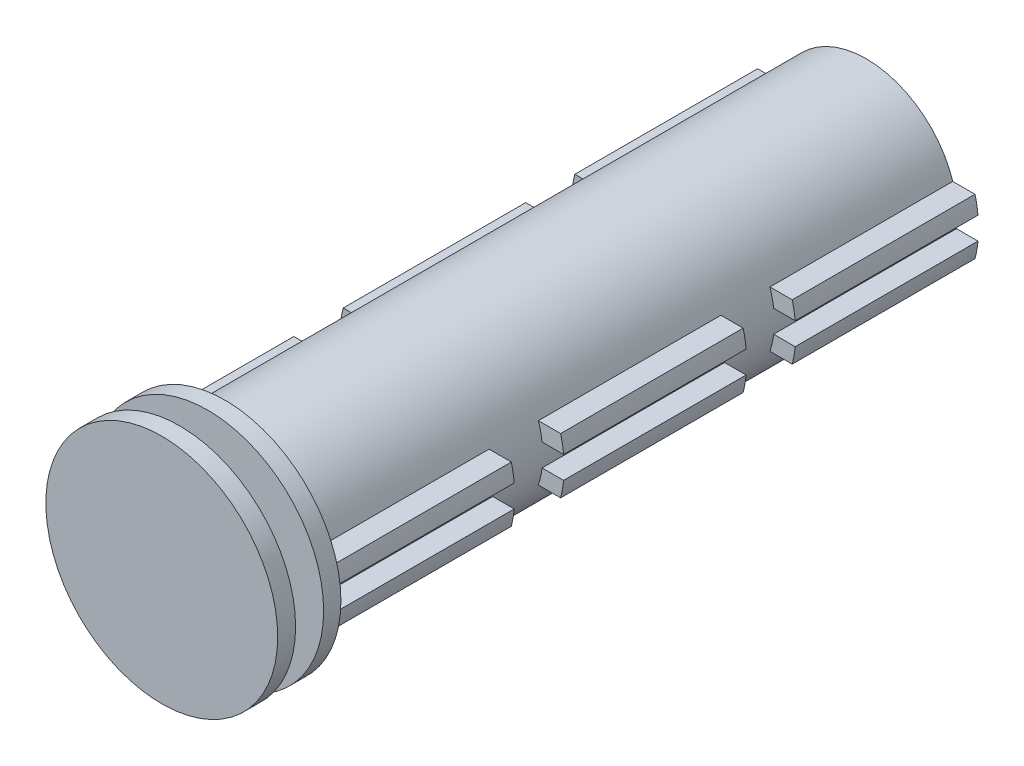
from build123d import *

# Parameters (mm, degrees)
SKETCH1_R           = 9.35355
BOSS_EXTRUDE1_DEPTH = 66.04
SKETCH7_R           = 11.938
BOSS_EXTRUDE4_DEPTH = 1.778
SKETCH14_R          = 7.71525
CUT_EXTRUDE1_DEPTH  = 66.04
SKETCH12_W          = 18.288
SKETCH12_H          = 1.7145
SKETCH12_H_2        = 1.707763716
SKETCH12_W_2        = 18.824802472
SKETCH12_W_3        = 18.796
BOSS_EXTRUDE5_DEPTH = 2.8448
CUT_EXTRUDE2_DEPTH  = 66.04
SKETCH21_R          = 7.399529871
BOSS_EXTRUDE7_DEPTH = 2.8448
SKETCH22_R          = 11.938
BOSS_EXTRUDE8_DEPTH = 1.8415
CUT_EXTRUDE3_DEPTH  = 66.04


with BuildPart() as part:
    # Sketch1 → Boss-Extrude1 (new body)
    with BuildSketch(Plane.XY):
        with Locations((-78.519529871, 2.741262574)):
            Circle(SKETCH1_R)
    extrude(amount=BOSS_EXTRUDE1_DEPTH)

    # Sketch7 → Boss-Extrude4 (add)
    with BuildSketch(Plane.XY.offset(66.04)):
        with Locations((-78.519529871, 2.741262574)):
            Circle(SKETCH7_R)
    extrude(amount=BOSS_EXTRUDE4_DEPTH)

    # Sketch14 → Cut-Extrude1 (cut)
    with BuildSketch(Plane(origin=(0, 0, 0), x_dir=(-1, 0, 0), z_dir=(0, 0, -1))):
        with Locations((78.519529871, 2.741262574)):
            Circle(SKETCH14_R)
    extrude(amount=-CUT_EXTRUDE1_DEPTH, mode=Mode.SUBTRACT)

    # Sketch12 → Boss-Extrude5 (add)
    with BuildSketch(Plane(origin=(-69.85, 0, 0), x_dir=(0, 0, -1), z_dir=(1, 0, 0))):
        with Locations((-56.896, 4.754212574)):
            Rectangle(SKETCH12_W, SKETCH12_H)
        with Locations((-56.896, 0.724944432)):
            Rectangle(SKETCH12_W, SKETCH12_H_2)
        with Locations((-9.412401236, 0.728312574)):
            Rectangle(SKETCH12_W_2, SKETCH12_H)
        with Locations((-9.412401236, 4.754212574)):
            Rectangle(SKETCH12_W_2, SKETCH12_H)
        with Locations((-33.274, 0.728312574)):
            Rectangle(SKETCH12_W_3, SKETCH12_H)
        with Locations((-33.274, 4.754212574)):
            Rectangle(SKETCH12_W_3, SKETCH12_H)
    boss_extrude5 = extrude(amount=BOSS_EXTRUDE5_DEPTH)

    # Mirror2: Boss-Extrude5 across plane
    add(boss_extrude5.mirror(Plane(origin=(-78.5622, 0, 0), x_dir=(0, 0, 1), z_dir=(1, 0, 0))))

    # Sketch19 → Cut-Extrude2 (cut)
    with BuildSketch(Plane(origin=(0, 0, 0), x_dir=(-1, 0, 0), z_dir=(0, 0, -1))):
        with BuildLine():
            Line((67.02046006, 3.896962574), (67.0052, 3.896962574))
            Line((67.0052, 3.896962574), (67.0052, 5.611462574))
            Line((67.0052, 5.611462574), (67.324611338, 5.611462574))
            ThreePointArc((67.324611338, 5.611462574), (67.140199737, 4.759948955), (67.02046006, 3.896962574))
        make_face()
        with BuildLine():
            Line((67.0052, 1.585562574), (67.02046006, 1.585562574))
            ThreePointArc((67.02046006, 1.585562574), (67.140199737, 0.722576194), (67.324611338, -0.128937426))
            Line((67.324611338, -0.128937426), (67.0052, -0.128937426))
            Line((67.0052, -0.128937426), (67.0052, 1.585562574))
        make_face()
        with BuildLine():
            Line((90.1192, 5.611462574), (89.714448404, 5.611462574))
            ThreePointArc((89.714448404, 5.611462574), (89.898860005, 4.759948955), (90.018599681, 3.896962574))
            Line((90.018599681, 3.896962574), (90.1192, 3.896962574))
            Line((90.1192, 3.896962574), (90.1192, 5.611462574))
        make_face()
        with BuildLine():
            Line((89.714448404, -0.128937426), (90.1192, -0.128937426))
            Line((90.1192, -0.128937426), (90.1192, 1.585562574))
            Line((90.1192, 1.585562574), (90.017920666, 1.57882629))
            ThreePointArc((90.017920666, 1.57882629), (89.898268214, 0.719243113), (89.714448404, -0.128937426))
        make_face()
    extrude(amount=-CUT_EXTRUDE2_DEPTH, mode=Mode.SUBTRACT)

    # Sketch21 → Boss-Extrude7 (add)
    with BuildSketch(Plane.XY.offset(67.818)):
        with Locations((-78.5622, 2.741262574)):
            Circle(SKETCH21_R)
    extrude(amount=BOSS_EXTRUDE7_DEPTH)

    # Sketch22 → Boss-Extrude8 (add)
    with BuildSketch(Plane.XY.offset(70.6628)):
        with Locations((-78.5622, 2.741262574)):
            Circle(SKETCH22_R)
    extrude(amount=BOSS_EXTRUDE8_DEPTH)

    # Sketch17 → Cut-Extrude3 (cut)
    with BuildSketch(Plane(origin=(0, 0, 0), x_dir=(-1, 0, 0), z_dir=(0, 0, -1))):
        with BuildLine():
            Line((75.979529871, -5.342287426), (75.979529871, -6.260809276))
            ThreePointArc((75.979529871, -6.260809276), (78.519529871, -6.612287426), (81.059529871, -6.260809276))
            Line((81.059529871, -6.260809276), (81.059529871, -5.342287426))
            Line((81.059529871, -5.342287426), (75.979529871, -5.342287426))
        make_face()
    extrude(amount=-CUT_EXTRUDE3_DEPTH, mode=Mode.SUBTRACT)


solid = part.part
